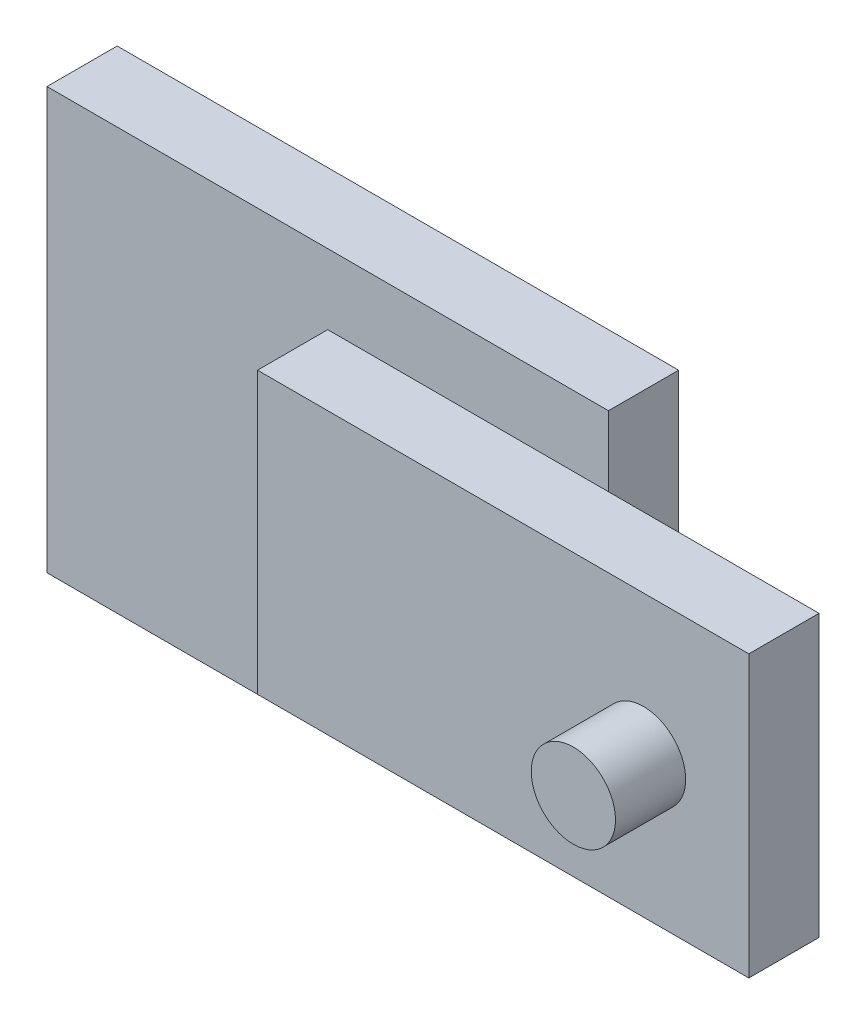
from build123d import *

# Parameters (mm, degrees)
CROQUIS1_W              = 80
CROQUIS1_H              = 60
SALIENTE_EXTRUIR1_DEPTH = 10
CROQUIS2_W              = 70
CROQUIS2_H              = 40
SALIENTE_EXTRUIR2_DEPTH = 10
CROQUIS3_R              = 6
SALIENTE_EXTRUIR3_DEPTH = 10


with BuildPart() as part:
    # Croquis1 → Saliente-Extruir1 (new body)
    with BuildSketch(Plane.XY):
        Rectangle(CROQUIS1_W, CROQUIS1_H)
    extrude(amount=SALIENTE_EXTRUIR1_DEPTH)

    # Croquis2 → Saliente-Extruir2 (add)
    with BuildSketch(Plane.XY.offset(10)):
        with Locations((35, 0)):
            Rectangle(CROQUIS2_W, CROQUIS2_H)
    extrude(amount=SALIENTE_EXTRUIR2_DEPTH)

    # Croquis3 → Saliente-Extruir3 (add)
    with BuildSketch(Plane.XY.offset(20)):
        with Locations((55, 0)):
            Circle(CROQUIS3_R)
    extrude(amount=SALIENTE_EXTRUIR3_DEPTH)


solid = part.part
